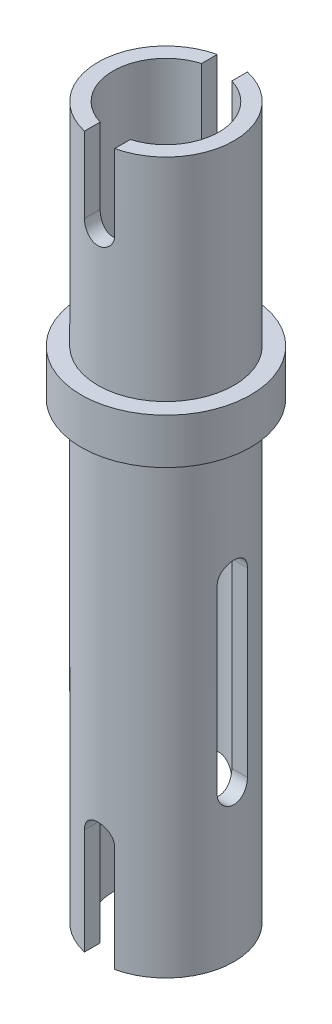
from build123d import *

# Parameters (mm, degrees)
SKETCH1_R           = 2.8
BOSS_EXTRUDE1_DEPTH = 1.5
SKETCH2_R           = 2.25
BOSS_EXTRUDE2_DEPTH = 7
SKETCH3_R           = 2.25
BOSS_EXTRUDE3_DEPTH = 15
CUT_EXTRUDE1_DEPTH  = 13.8
CUT_EXTRUDE2_DEPTH  = 13.8
SKETCH6_R           = 1.75
CUT_EXTRUDE3_DEPTH  = 26.0000001


with BuildPart() as part:
    # Sketch1 → Boss-Extrude1 (new body)
    with BuildSketch(Plane(origin=(0, 0, 0), x_dir=(1, 0, 0), z_dir=(0, 1, 0))):
        Circle(SKETCH1_R)
    extrude(amount=BOSS_EXTRUDE1_DEPTH)

    # Sketch2 → Boss-Extrude2 (add)
    with BuildSketch(Plane(origin=(0, 1.5, 0), x_dir=(1, 0, 0), z_dir=(0, 1, 0))):
        Circle(SKETCH2_R)
    extrude(amount=BOSS_EXTRUDE2_DEPTH)

    # Sketch3 → Boss-Extrude3 (add)
    with BuildSketch(Plane.XZ):
        Circle(SKETCH3_R)
    extrude(amount=BOSS_EXTRUDE3_DEPTH)

    # Sketch4 → Cut-Extrude1 (cut, through all)
    with BuildSketch(Plane.XY.offset(10)):
        with BuildLine():
            Line((-0.5, 6), (-0.5, 8.5))
            ThreePointArc((-0.5, 8.5), (0, 9), (0.5, 8.5))
            Line((0.5, 8.5), (0.5, 6))
            ThreePointArc((0.5, 6), (0, 5.5), (-0.5, 6))
        make_face()
        with BuildLine():
            Line((0.5, -11.5), (0.5, -15))
            ThreePointArc((0.5, -15), (0, -15.5), (-0.5, -15))
            Line((-0.5, -15), (-0.5, -11.5))
            ThreePointArc((-0.5, -11.5), (0, -11), (0.5, -11.5))
        make_face()
    extrude(amount=-CUT_EXTRUDE1_DEPTH, mode=Mode.SUBTRACT)

    # Sketch5 → Cut-Extrude2 (cut, through all)
    with BuildSketch(Plane(origin=(10, 0, 0), x_dir=(0, 0, -1), z_dir=(1, 0, 0))):
        with BuildLine():
            Line((0.5, -4), (0.5, -10))
            ThreePointArc((0.5, -10), (0, -10.5), (-0.5, -10))
            Line((-0.5, -10), (-0.5, -4))
            ThreePointArc((-0.5, -4), (0, -3.5), (0.5, -4))
        make_face()
    extrude(amount=-CUT_EXTRUDE2_DEPTH, mode=Mode.SUBTRACT)

    # Sketch6 → Cut-Extrude3 (cut, through all)
    with BuildSketch(Plane(origin=(0, 10, 0), x_dir=(1, 0, 0), z_dir=(0, 1, 0))):
        Circle(SKETCH6_R)
    extrude(amount=-CUT_EXTRUDE3_DEPTH, mode=Mode.SUBTRACT)


solid = part.part
